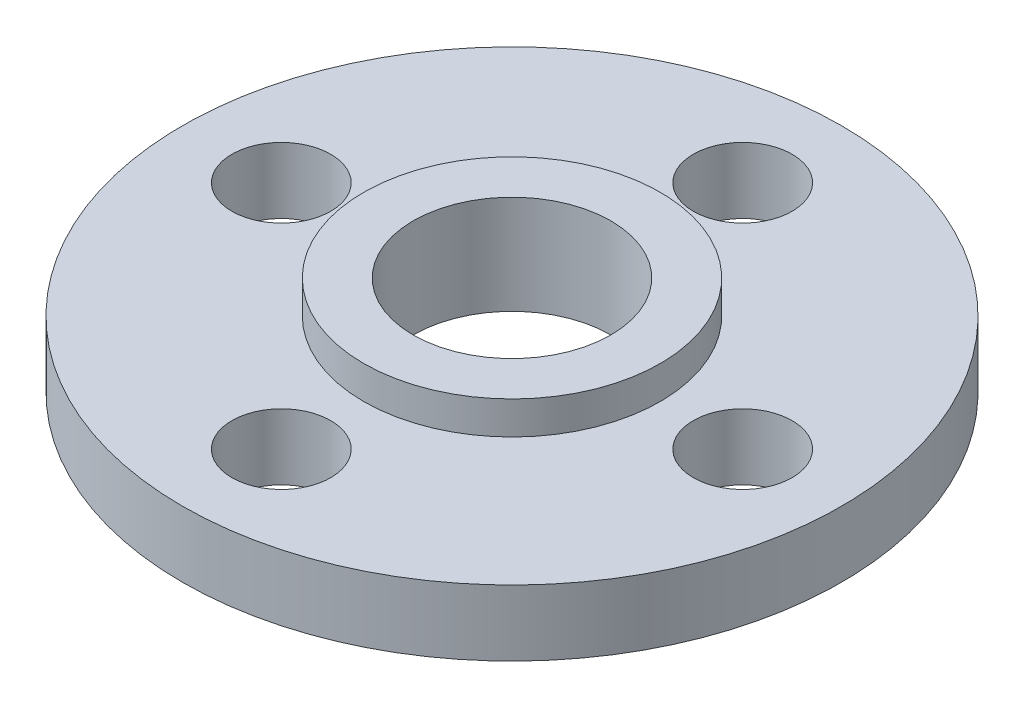
from build123d import *

# Parameters (mm, degrees)
SKETCH_1_R          = 10
EXTRUDE_1_DEPTH     = 2
SKETCH_2_R          = 3
SKETCH_2_R_2        = 1.5
CUT_EXTRUDE_1_DEPTH = 2
SKETCH_3_R          = 4.5
SKETCH_3_R_2        = 3
EXTRUDE_2_DEPTH     = 1


with BuildPart() as part:
    # 草图1 → 凸台-拉伸1 (new body)
    with BuildSketch(Plane(origin=(0, 0, 0), x_dir=(1, 0, 0), z_dir=(0, 1, 0))):
        Circle(SKETCH_1_R)
    extrude(amount=EXTRUDE_1_DEPTH)

    # 草图2 → 切除-拉伸1 (cut)
    with BuildSketch(Plane(origin=(0, 2, 0), x_dir=(1, 0, 0), z_dir=(0, 1, 0))):
        Circle(SKETCH_2_R)
        with Locations((0, 7)):
            Circle(SKETCH_2_R_2)
        with Locations((7, 0)):
            Circle(SKETCH_2_R_2)
        with Locations((0, -7)):
            Circle(SKETCH_2_R_2)
        with Locations((-7, 0)):
            Circle(SKETCH_2_R_2)
    extrude(amount=-CUT_EXTRUDE_1_DEPTH, mode=Mode.SUBTRACT)

    # 草图3 → 凸台-拉伸2 (add)
    with BuildSketch(Plane(origin=(0, 2, 0), x_dir=(1, 0, 0), z_dir=(0, 1, 0))):
        Circle(SKETCH_3_R)
        Circle(SKETCH_3_R_2, mode=Mode.SUBTRACT)
    extrude(amount=EXTRUDE_2_DEPTH)


solid = part.part
